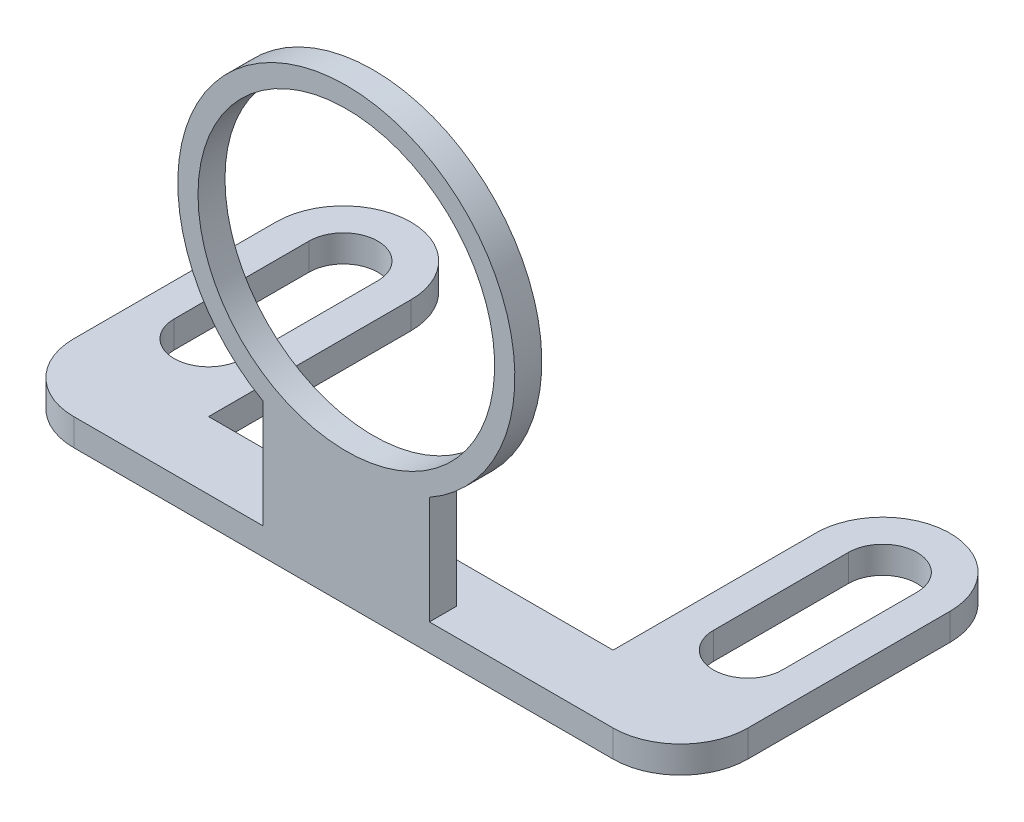
from build123d import *

# Parameters (mm, degrees)
BOSS_EXTRUDE1_DEPTH = 2
SKETCH2_R           = 11
BOSS_EXTRUDE3_DEPTH = 2


with BuildPart() as part:
    # Sketch1 → Boss-Extrude1 (new body)
    with BuildSketch(Plane(origin=(0, 0, 0), x_dir=(1, 0, 0), z_dir=(0, 1, 0))):
        with BuildLine():
            Line((-50.675392178, 10), (-50.675392178, 25))
            ThreePointArc((-50.675392178, 25), (-45.675392178, 30), (-40.675392178, 25))
            Line((-40.675392178, 25), (-40.675392178, 10))
            Line((-40.675392178, 10), (-10.675392178, 10))
            Line((-10.675392178, 10), (-10.675392178, 24.667030171))
            ThreePointArc((-10.675392178, 24.667030171), (-5.847512802, 30.002770955), (-0.675392178, 25))
            Line((-0.675392178, 25), (-0.675392178, 10))
            ThreePointArc((-0.675392178, 10), (-2.139858272, 6.464466094), (-5.675392178, 5))
            Line((-5.675392178, 5), (-45.675392178, 5))
            ThreePointArc((-45.675392178, 5), (-49.210926084, 6.464466094), (-50.675392178, 10))
        make_face()
        with BuildLine():
            Line((-43.125392178, 25), (-43.125392178, 15))
            ThreePointArc((-43.125392178, 15), (-45.675392178, 12.45), (-48.225392178, 15))
            Line((-48.225392178, 15), (-48.225392178, 25))
            ThreePointArc((-48.225392178, 25), (-45.675392178, 27.55), (-43.125392178, 25))
        make_face(mode=Mode.SUBTRACT)
        with BuildLine():
            Line((-8.225392178, 25), (-8.225392178, 15))
            ThreePointArc((-8.225392178, 15), (-5.675392178, 12.45), (-3.125392178, 15))
            Line((-3.125392178, 15), (-3.125392178, 25))
            ThreePointArc((-3.125392178, 25), (-5.675392178, 27.55), (-8.225392178, 25))
        make_face(mode=Mode.SUBTRACT)
    extrude(amount=BOSS_EXTRUDE1_DEPTH)

    # Sketch2 → Boss-Extrude3 (add)
    with BuildSketch(Plane(origin=(0, 0, -5), x_dir=(-1, 0, 0), z_dir=(0, 0, -1))):
        with BuildLine():
            Line((19.297037413, 10.004378208), (19.297037413, 2))
            Line((19.297037413, 2), (31.622351713, 2))
            Line((31.622351713, 2), (31.622351713, 10.004378208))
            ThreePointArc((31.622351713, 10.004378208), (25.459694563, 33.379655531), (19.297037413, 10.004378208))
        make_face()
        with Locations((25.459694563, 20.879655531)):
            Circle(SKETCH2_R, mode=Mode.SUBTRACT)
    extrude(amount=BOSS_EXTRUDE3_DEPTH)


solid = part.part
